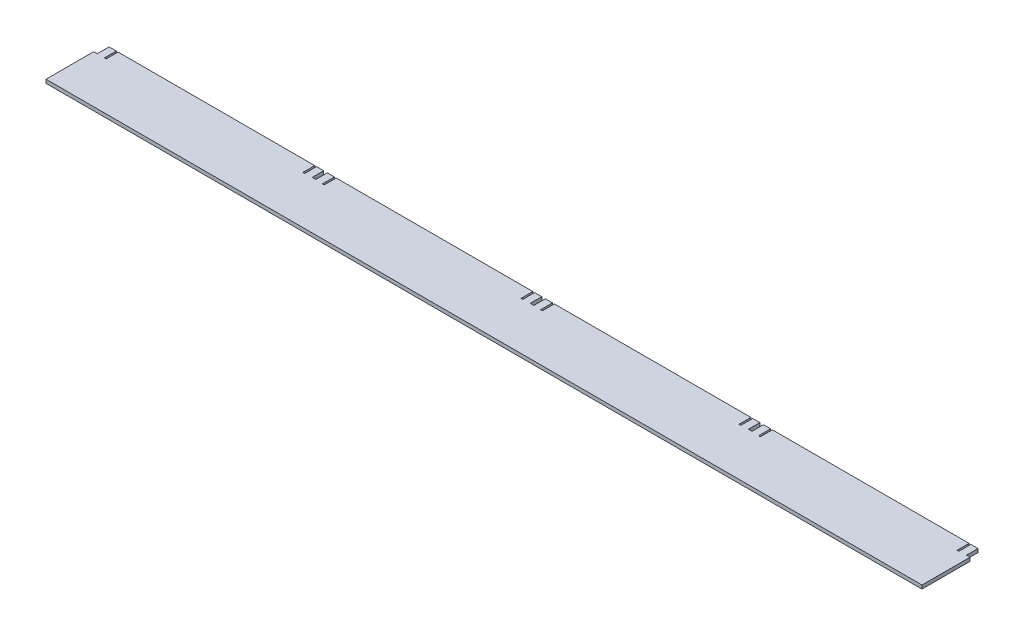
from build123d import *

# Parameters (mm, degrees)
BOSS_EXTRUDE1_DEPTH = 1.5
SKETCH2_W           = 3
SKETCH2_H           = 40.331406252
BOSS_EXTRUDE2_DEPTH = 1.5
LPATTERN2_COUNT     = 4
LPATTERN2_PITCH     = 183
SKETCH3_W           = 3
SKETCH3_H           = 40
BOSS_EXTRUDE3_DEPTH = 1.5


with BuildPart() as part:
    # Sketch1 → Boss-Extrude1 (new body, symmetric)
    with BuildSketch(Plane(origin=(0, 0, 0), x_dir=(1, 0, 0), z_dir=(0, 1, 0))):
        Polygon((-84, 25), (-84, 15), (-82.5, 15), (-82.5, 25), (82.5, 25), (82.5, 15), (84, 15), (84, 25), (90, 25), (90, -25), (-90, -25), (-90, 25), align=None)
    boss_extrude1 = extrude(amount=BOSS_EXTRUDE1_DEPTH, both=True)

    # Sketch2 → Boss-Extrude2 (add, symmetric)
    with BuildSketch(Plane(origin=(0, 0, 0), x_dir=(1, 0, 0), z_dir=(0, 1, 0))):
        with Locations((91.5, -4.834296874)):
            Rectangle(SKETCH2_W, SKETCH2_H)
    boss_extrude2 = extrude(amount=BOSS_EXTRUDE2_DEPTH, both=True)

    # LPattern2: Boss-Extrude1, Boss-Extrude2 ×4
    with Locations(*[(i * LPATTERN2_PITCH, 0, 0) for i in range(1, LPATTERN2_COUNT)]):
        add(boss_extrude1)
        add(boss_extrude2)

    # Sketch3 → Boss-Extrude3 (add, symmetric)
    with BuildSketch(Plane(origin=(0, 0, 0), x_dir=(1, 0, 0), z_dir=(0, 1, 0))):
        with Locations((-91.5, -5)):
            Rectangle(SKETCH3_W, SKETCH3_H)
    extrude(amount=BOSS_EXTRUDE3_DEPTH, both=True)


solid = part.part
